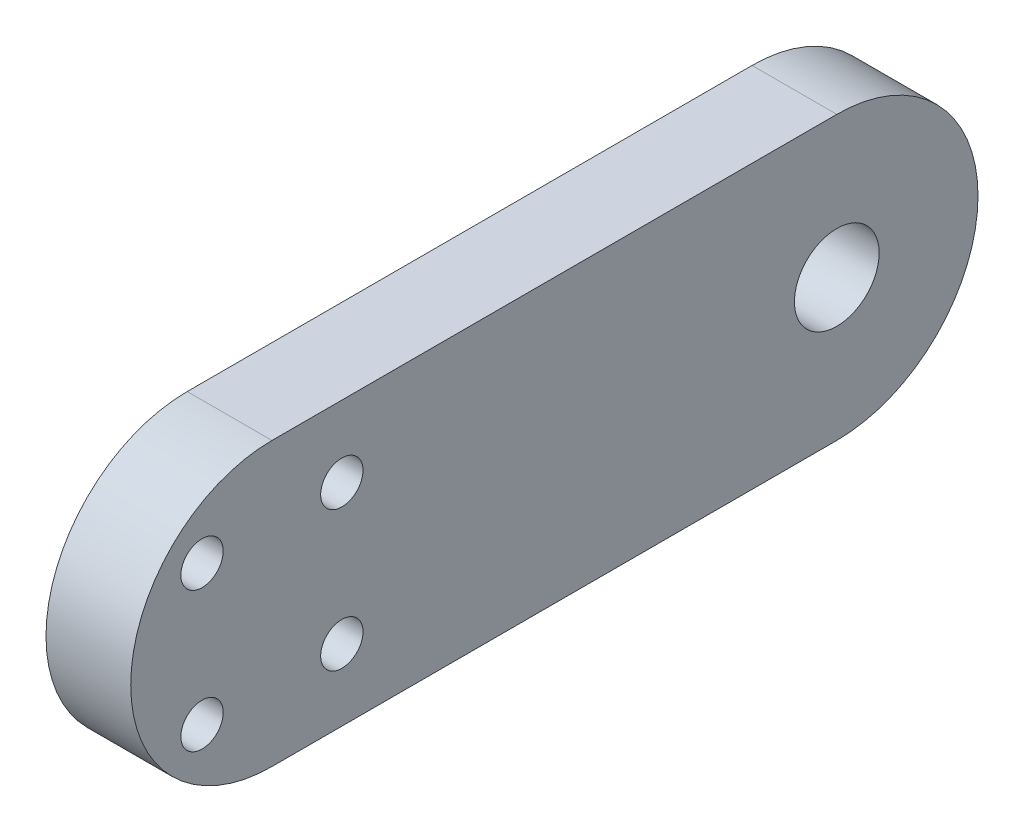
from build123d import *

# Parameters (mm, degrees)
BOSS_EXTRUDE1_DEPTH     = 3
CUT_EXTRUDE1_DEPTH      = 52.078371156
CUT_EXTRUDE1_DEPTH_BACK = 52.078371156
SKETCH2_R               = 1.5
CUT_EXTRUDE2_DEPTH      = 52.078371156
CUT_EXTRUDE2_DEPTH_BACK = 52.078371156
SKETCH3_R               = 3


with BuildPart() as part:
    # Sketch1 → Boss-Extrude1 (new, symmetric)
    with BuildSketch(Plane(origin=(0, 0, 0), x_dir=(0, 0, -1), z_dir=(1, 0, 0))):
        with BuildLine():
            Line((40, -10), (0, -10))
            ThreePointArc((0, -10), (-10, 0), (0, 10))
            Line((0, 10), (40, 10))
            ThreePointArc((40, 10), (50, 0), (40, -10))
        make_face()
    extrude(amount=BOSS_EXTRUDE1_DEPTH, both=True)

    # Sketch2 → Cut-Extrude1 (cut, two sides: drawn at the far end of the back side and taken through both)
    with BuildSketch(Plane(origin=(0, 0, 0), x_dir=(0, 0, -1), z_dir=(1, 0, 0)).offset(-CUT_EXTRUDE1_DEPTH_BACK)):
        with Locations((4.949747468, 4.949747468)):
            Circle(SKETCH2_R)
        with Locations((4.949747468, -4.949747468)):
            Circle(SKETCH2_R)
        with Locations((-4.949747468, -4.949747468)):
            Circle(SKETCH2_R)
        with Locations((-4.949747468, 4.949747468)):
            Circle(SKETCH2_R)
    extrude(amount=CUT_EXTRUDE1_DEPTH + CUT_EXTRUDE1_DEPTH_BACK, mode=Mode.SUBTRACT)

    # Sketch3 → Cut-Extrude2 (cut, two sides: drawn at the far end of the back side and taken through both)
    with BuildSketch(Plane(origin=(0, 0, 0), x_dir=(0, 0, -1), z_dir=(1, 0, 0)).offset(-CUT_EXTRUDE2_DEPTH_BACK)):
        with Locations((40, 0)):
            Circle(SKETCH3_R)
    extrude(amount=CUT_EXTRUDE2_DEPTH + CUT_EXTRUDE2_DEPTH_BACK, mode=Mode.SUBTRACT)


solid = part.part
